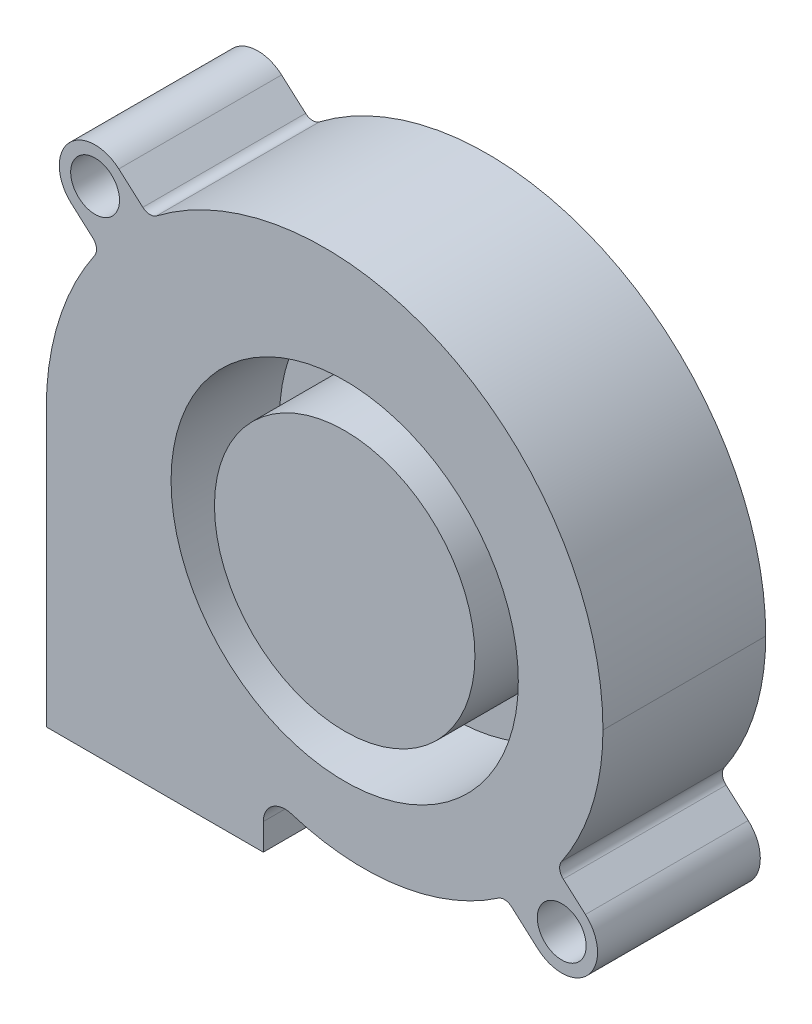
from build123d import *

# Parameters (mm, degrees)
SZKIC1_R                    = 2.25
DODANIE_WYCI_GNI_CIE1_DEPTH = 15
SZKIC2_R                    = 16
SZKIC2_R_2                  = 12
WYTNIJ_WYCI_GNI_CIE1_DEPTH  = 10


with BuildPart() as part:
    # Szkic1 → Dodanie-wyciągnięcie1 (new body)
    with BuildSketch(Plane.XY):
        with BuildLine():
            Line((-7.5, -25.4), (-27.5000055, -25.4))
            Line((-27.5000055, -25.4), (-27.5000055, 0))
            ThreePointArc((-27.5000055, 0), (-26.360400157, 7.560626052), (-23.04284729, 14.449429258))
            ThreePointArc((-23.04284729, 14.449429258), (-22.876506159, 15.134411684), (-23.203344978, 15.75894886))
            Line((-23.203344978, 15.75894886), (-25.196922194, 17.537575813))
            ThreePointArc((-25.196922194, 17.537575813), (-25.467611983, 22.191093586), (-20.814747272, 22.472785982))
            Line((-20.814747272, 22.472785982), (-18.598905377, 20.514600122))
            ThreePointArc((-18.598905377, 20.514600122), (-17.974550182, 20.264645495), (-17.333078903, 20.466663618))
            ThreePointArc((-17.333078903, 20.466663618), (9.576401492, 22.98111988), (23.8, 0))
            ThreePointArc((23.8, 0), (22.82107067, -6.492449946), (19.979075206, -12.411340949))
            ThreePointArc((19.979075206, -12.411340949), (19.813964518, -13.098271951), (20.143734708, -13.723081814))
            Line((20.143734708, -13.723081814), (22.185252728, -15.527214018))
            ThreePointArc((22.185252728, -15.527214018), (22.472785982, -20.185252728), (17.814747272, -20.472785982))
            Line((17.814747272, -20.472785982), (15.376980036, -18.318480053))
            ThreePointArc((15.376980036, -18.318480053), (14.777726241, -18.069792078), (14.151976117, -18.241220202))
            ThreePointArc((14.151976117, -18.241220202), (4.948796089, -21.832347138), (-4.899043329, -21.048271831))
            ThreePointArc((-4.899043329, -21.048271831), (-6.68281162, -21.343100938), (-7.5, -22.955849111))
            Line((-7.5, -22.955849111), (-7.5, -25.4))
        make_face()
        with Locations((-23, 20)):
            Circle(SZKIC1_R, mode=Mode.SUBTRACT)
        with Locations((20, -18)):
            Circle(SZKIC1_R, mode=Mode.SUBTRACT)
    extrude(amount=DODANIE_WYCI_GNI_CIE1_DEPTH)

    # Szkic2 → Wytnij-wyciągnięcie1 (cut)
    with BuildSketch(Plane.XY.offset(15)):
        Circle(SZKIC2_R)
        Circle(SZKIC2_R_2, mode=Mode.SUBTRACT)
    extrude(amount=-WYTNIJ_WYCI_GNI_CIE1_DEPTH, mode=Mode.SUBTRACT)


solid = part.part
